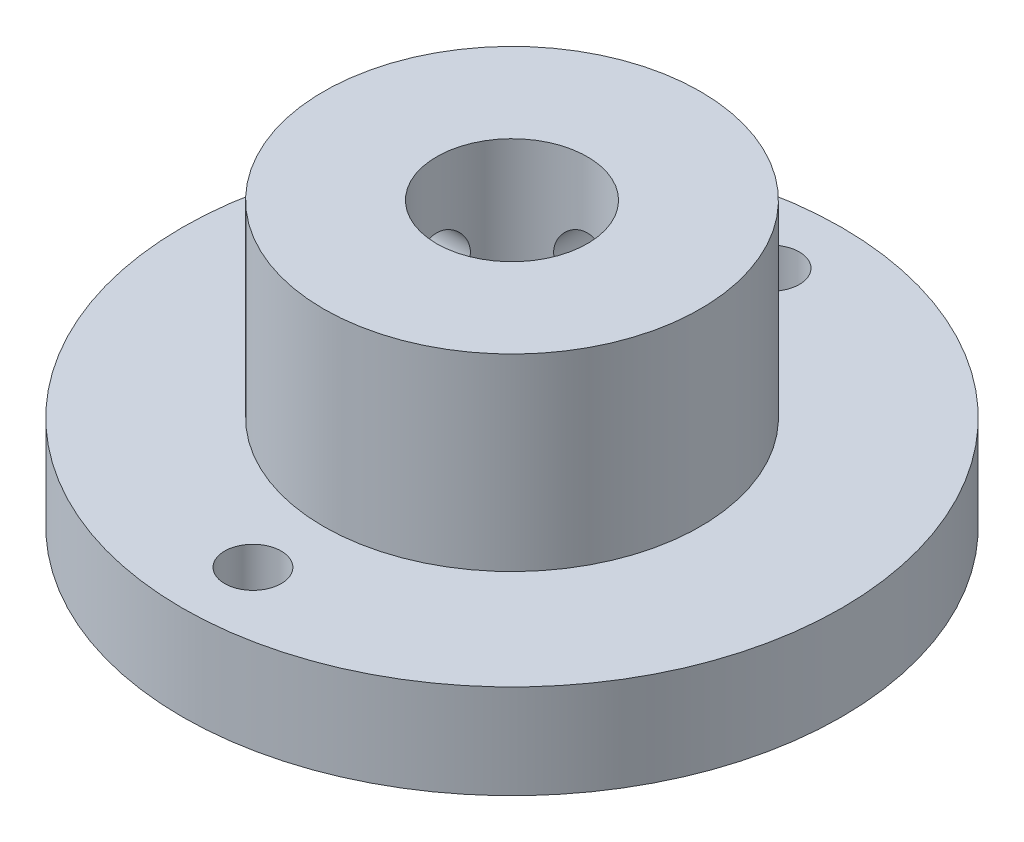
from build123d import *

# Parameters (mm, degrees)
ESBO_O1_R                = 17.5
RESSALTO_EXTRUS_O1_DEPTH = 5
ESBO_O2_R                = 10
RESSALTO_EXTRUS_O2_DEPTH = 10
ESBO_O3_R                = 4
CORTE_EXTRUS_O1_DEPTH    = 16
ESBO_O4_R                = 1.5
CORTE_EXTRUS_O2_DEPTH    = 10
ESBO_O5_R                = 1.5
CORTE_EXTRUS_O3_DEPTH    = 18.5
ESBO_O6_R                = 1.5
CORTE_EXTRUS_O4_DEPTH    = 18.5


with BuildPart() as part:
    # Esboço1 → Ressalto-extrusão1 (new body)
    with BuildSketch(Plane(origin=(0, 0, 0), x_dir=(1, 0, 0), z_dir=(0, 1, 0))):
        Circle(ESBO_O1_R)
    extrude(amount=RESSALTO_EXTRUS_O1_DEPTH)

    # Esboço2 → Ressalto-extrusão2 (add)
    with BuildSketch(Plane(origin=(0, 5, 0), x_dir=(1, 0, 0), z_dir=(0, 1, 0))):
        Circle(ESBO_O2_R)
    extrude(amount=RESSALTO_EXTRUS_O2_DEPTH)

    # Esboço3 → Corte-extrusão1 (cut, through all)
    with BuildSketch(Plane(origin=(0, 15, 0), x_dir=(1, 0, 0), z_dir=(0, 1, 0))):
        Circle(ESBO_O3_R)
    extrude(amount=-CORTE_EXTRUS_O1_DEPTH, mode=Mode.SUBTRACT)

    # Esboço4 → Corte-extrusão2 (cut)
    with BuildSketch(Plane(origin=(0, 5, 0), x_dir=(1, 0, 0), z_dir=(0, 1, 0))):
        with Locations((0, 13.75)):
            Circle(ESBO_O4_R)
        with Locations((0, -13.75)):
            Circle(ESBO_O4_R)
    extrude(amount=-CORTE_EXTRUS_O2_DEPTH, mode=Mode.SUBTRACT)

    # Esboço5 → Corte-extrusão3 (cut, through all)
    with BuildSketch(Plane.XY):
        with Locations((0, 10)):
            Circle(ESBO_O5_R)
    extrude(amount=-CORTE_EXTRUS_O3_DEPTH, mode=Mode.SUBTRACT)

    # Esboço6 → Corte-extrusão4 (cut, through all)
    with BuildSketch(Plane(origin=(0, 0, 0), x_dir=(0, 0, -1), z_dir=(1, 0, 0))):
        with Locations((0, 10)):
            Circle(ESBO_O6_R)
    extrude(amount=-CORTE_EXTRUS_O4_DEPTH, mode=Mode.SUBTRACT)


solid = part.part
